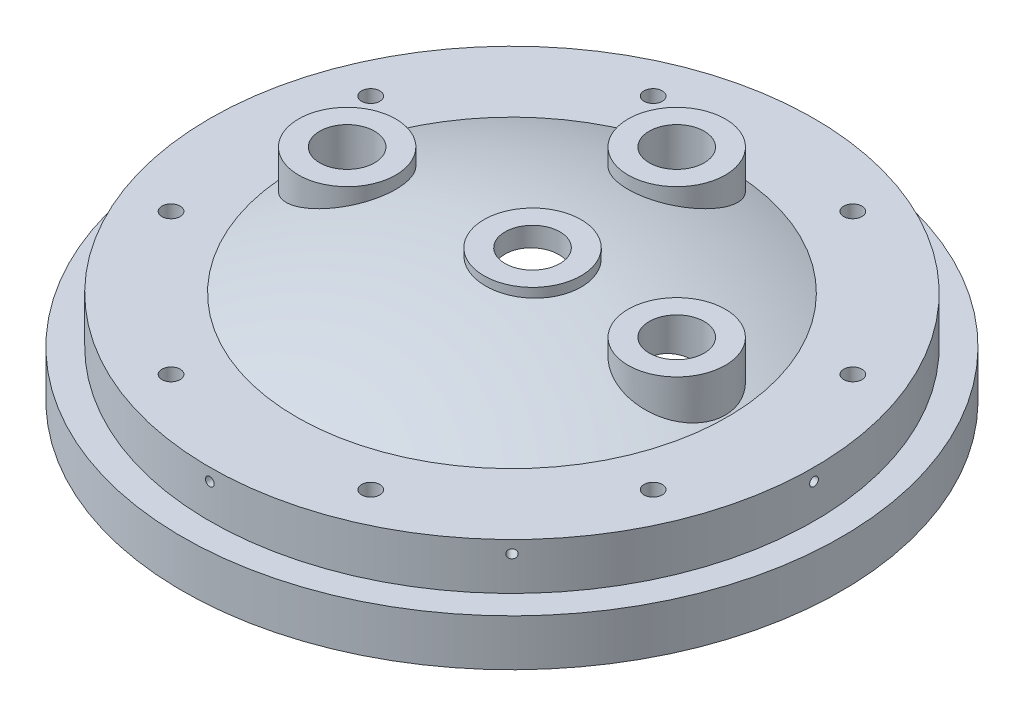
from build123d import *

# Parameters (mm, degrees)
CIRPATTERN1_COUNT                    = 8
SKETCH8_R                            = 22.479
BOSS_EXTRUDE1_DEPTH                  = 2.54
BOSS_EXTRUDE1_DIRECTION_2_REACH      = 226.686
BOSS_EXTRUDE1_DIRECTION_2_END_RADIUS = 254
BOSS_EXTRUDE2_REACH                  = 226.686
BOSS_EXTRUDE2_END_RADIUS             = 254
SKETCH9_R                            = 22.479
HOLE1_D                              = 25.4
HOLE1_DEPTH                          = 25.4
HOLE2_D                              = 25.4
HOLE2_DEPTH                          = 25.4
CIRPATTERN2_COUNT                    = 3
CIRPATTERN2_ANGLE                    = 180
CIRPATTERN3_COUNT                    = 8


with BuildPart() as part:
    # Sketch1 → Revolve1 (revolve)
    with BuildSketch(Plane.XY, mode=Mode.PRIVATE) as revolve1_sk:
        with BuildLine():
            Line((146.05, 0), (152.4, 0))
            Line((152.4, 0), (152.4, 21.59))
            Line((152.4, 21.59), (139.7, 21.59))
            Line((139.7, 21.59), (139.7, 43.18))
            Line((139.7, 43.18), (99.547263147, 43.18))
            ThreePointArc((99.547263147, 43.18), (50.8, 58.368157867), (0, 63.5))
            Line((0, 63.5), (0, 57.15))
            ThreePointArc((0, 57.15), (76.813319255, 44.936268415), (146.05, 9.4998))
            Line((146.05, 9.4998), (146.05, 0))
        make_face()
    revolve(revolve1_sk.sketch.rotate(Axis((0, 63.5, 0), (0, -1, 0)), 180), axis=Axis((0, 63.5, 0), (0, -1, 0)))

    # Sketch5 → Tap Drill for #10-32 Tap1 (revolve, cut)
    with BuildSketch(Plane(origin=(139.7, 37.465, 0), x_dir=(0, 0, -1), z_dir=(0, 1, 0))):
        Polygon((0, 0), (0, 11.373317848), (2.0193, 10.16), (2.0193, 0), align=None)
    tap_drill_for_10_32_tap1 = revolve(axis=Axis((146.05, 37.465, 0), (-1, 0, 0)), mode=Mode.SUBTRACT)

    # CirPattern1: Tap Drill for #10-32 Tap1 ×8 about axis
    cirpattern1_axis = Axis((0, 21.59, 0), (0, 1, 0))
    for i in range(1, CIRPATTERN1_COUNT):
        add(tap_drill_for_10_32_tap1.rotate(cirpattern1_axis, i * 360 / CIRPATTERN1_COUNT), mode=Mode.SUBTRACT)


with BuildPart() as boss_extrude1_tool:
    # Sketch8 → Boss-Extrude1 (new body)
    with BuildSketch(Plane(origin=(0, 63.5, 0), x_dir=(1, 0, 0), z_dir=(0, 1, 0))):
        with Locations(Location((9.525, 0, 0), (0, 0, 270))):
            Circle(SKETCH8_R)
    extrude(amount=BOSS_EXTRUDE1_DEPTH)


with BuildPart() as part_1:
    add(part.part)


with BuildPart() as part_2:
    # Boss-Extrude1: joined with boss_extrude1_tool
    add(part_1.part.fuse(boss_extrude1_tool.part, tol=0.00001))

    # Boss-Extrude1 direction 2: up to this sphere (the profile starts outside it)
    boss_extrude1_direction_2_end = Location((0, -190.5, 0)) * Sphere(BOSS_EXTRUDE1_DIRECTION_2_END_RADIUS, mode=Mode.PRIVATE)
    # Sketch8 → Boss-Extrude1 direction 2 (add, up to the surface)
    with BuildSketch(Plane(origin=(0, 63.5, 0), x_dir=(1, 0, 0), z_dir=(0, 1, 0)), mode=Mode.PRIVATE) as boss_extrude1_direction_2_sk1:
        with Locations(Location((9.525, 0, 0), (0, 0, 270))):
            Circle(SKETCH8_R)
    boss_extrude1_direction_2_tool1 = extrude(boss_extrude1_direction_2_sk1.sketch, amount=-BOSS_EXTRUDE1_DIRECTION_2_REACH, mode=Mode.PRIVATE) - boss_extrude1_direction_2_end
    add(boss_extrude1_direction_2_tool1.solids().sort_by_distance((9.525, 63.5, 0))[0])

    # Boss-Extrude2: up to this sphere (the profile starts outside it)
    boss_extrude2_end = Location((0, -190.5, 0)) * Sphere(BOSS_EXTRUDE2_END_RADIUS, mode=Mode.PRIVATE)
    # Sketch9 → Boss-Extrude2 (add, up to the surface)
    with BuildSketch(Plane(origin=(0, 63.5, 0), x_dir=(1, 0, 0), z_dir=(0, 1, 0)), mode=Mode.PRIVATE) as boss_extrude2_sk1:
        with Locations(Location((76.2, 0, 0), (0, 0, 270))):
            Circle(SKETCH9_R)
    boss_extrude2_tool1 = extrude(boss_extrude2_sk1.sketch, amount=-BOSS_EXTRUDE2_REACH, mode=Mode.PRIVATE) - boss_extrude2_end
    boss_extrude2 = boss_extrude2_tool1.solids().sort_by_distance((76.2, 63.5, 0))[0]
    add(boss_extrude2)

    # Hole1
    with Locations(Plane(origin=(0, 66.04, 0), x_dir=(1, 0, 0), z_dir=(0, 1, 0))):
        with Locations((9.525, 0)):
            Hole(HOLE1_D / 2, depth=HOLE1_DEPTH)

    # Hole2
    with Locations(Plane(origin=(0, 63.5, 0), x_dir=(1, 0, 0), z_dir=(0, 1, 0))):
        with Locations((76.2, 0)):
            hole2 = Hole(HOLE2_D / 2, depth=HOLE2_DEPTH)

    # CirPattern2: Boss-Extrude2, Hole2 ×3 about axis
    cirpattern2_axis = Axis((0, 0, 0), (0, 1, 0))
    add([boss_extrude2.rotate(cirpattern2_axis, i * CIRPATTERN2_ANGLE / (CIRPATTERN2_COUNT - 1)) for i in range(1, CIRPATTERN2_COUNT)])
    add([hole2.rotate(cirpattern2_axis, i * CIRPATTERN2_ANGLE / (CIRPATTERN2_COUNT - 1)) for i in range(1, CIRPATTERN2_COUNT)], mode=Mode.SUBTRACT)

    # Sketch19 → 3/8-24 Tapped Hole1 (revolve, cut)
    with BuildSketch(Plane(origin=(111.466065597, 43.18, -46.170756115), x_dir=(0, 0, 1), z_dir=(1, 0, 0))):
        Polygon((0, 0), (0, 11.423468714), (4.2164, 8.89), (4.2164, 0), align=None)
    f_3_8_24_tapped_hole1 = revolve(axis=Axis((111.466065597, 49.53, -46.170756115), (0, -1, 0)), mode=Mode.SUBTRACT)

    # CirPattern3: 3/8-24 Tapped Hole1 ×8 about axis
    cirpattern3_axis = Axis((0, 0, 0), (0, 1, 0))
    for i in range(1, CIRPATTERN3_COUNT):
        add(f_3_8_24_tapped_hole1.rotate(cirpattern3_axis, i * 360 / CIRPATTERN3_COUNT), mode=Mode.SUBTRACT)


solid = part_2.part
